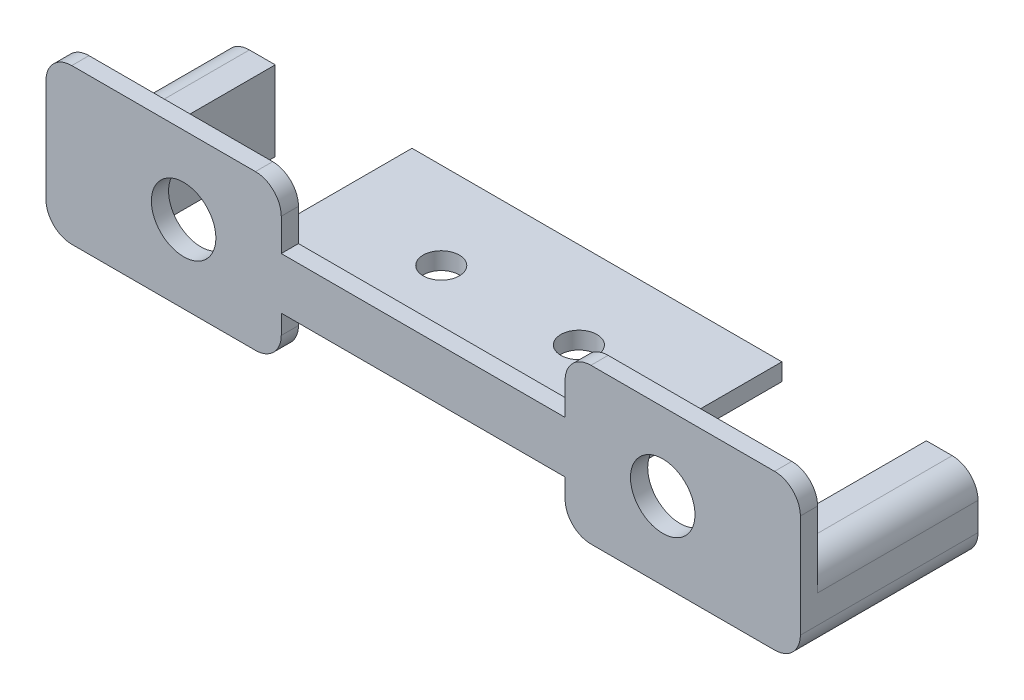
from build123d import *

# Parameters (mm, degrees)
SKETCH3_W           = 43
SKETCH3_H           = 18.2
SKETCH3_R           = 2.1
BOSS_EXTRUDE5_DEPTH = 2
SKETCH1_R           = 3.75
BOSS_EXTRUDE1_DEPTH = 2
CHAMFER1_SIZE       = 1.5
SKETCH5_W           = 6
SKETCH5_H           = 9.25
BOSS_EXTRUDE4_DEPTH = 18.65
FILLET1_R           = 3


with BuildPart() as part:
    # Sketch3 → Boss-Extrude5 (new body)
    with BuildSketch(Plane(origin=(0, 0, 0), x_dir=(1, 0, 0), z_dir=(0, 1, 0))):
        with Locations((0, 9.1)):
            Rectangle(SKETCH3_W, SKETCH3_H)
        with Locations((-8, 8.1)):
            Circle(SKETCH3_R, mode=Mode.SUBTRACT)
        with Locations((8, 8.1)):
            Circle(SKETCH3_R, mode=Mode.SUBTRACT)
    extrude(amount=-BOSS_EXTRUDE5_DEPTH)

    # Sketch1 → Boss-Extrude1 (add)
    with BuildSketch(Plane.XY):
        Polygon((-43.85, -9.25), (-16.5, -9.25), (-16.5, -4), (16.5, -4), (16.5, -9.25), (43.85, -9.25), (43.85, 8.75), (16.5, 8.75), (16.5, 2), (-16.5, 2), (-16.5, 8.75), (-43.85, 8.75), align=None)
        with Locations((-27.85, -0.25)):
            Circle(SKETCH1_R, mode=Mode.SUBTRACT)
        with Locations((27.85, -0.25)):
            Circle(SKETCH1_R, mode=Mode.SUBTRACT)
    extrude(amount=BOSS_EXTRUDE1_DEPTH)

    # Chamfer1
    chamfer1_edges = [part.edges().sort_by_distance(p)[0] for p in [
        (0, -2, 0),
    ]]
    chamfer(chamfer1_edges, length=CHAMFER1_SIZE)

    # Sketch5 → Boss-Extrude4 (add)
    with BuildSketch(Plane(origin=(0, 0, 0), x_dir=(-1, 0, 0), z_dir=(0, 0, -1))):
        with Locations((40.85, -4.625)):
            Rectangle(SKETCH5_W, SKETCH5_H)
    boss_extrude4 = extrude(amount=BOSS_EXTRUDE4_DEPTH)

    # Mirror2: Boss-Extrude4 across plane
    add(boss_extrude4.mirror(Plane(origin=(0, 0, 0), x_dir=(0, 0, 1), z_dir=(1, 0, 0))))

    # Fillet1
    fillet1_edges = [part.edges().sort_by_distance(p)[0] for p in [
        (-43.85, 8.75, 1),
        (-43.85, -9.25, -8.325),
        (-16.5, -9.25, 1),
        (16.5, -9.25, 1),
        (43.85, -9.25, -8.325),
        (43.85, 8.75, 1),
        (16.5, 8.75, 1),
        (-16.5, 8.75, 1),
        (-43.85, 0, -9.325),
        (43.85, 0, -9.325),
    ]]
    fillet(fillet1_edges, radius=FILLET1_R)


solid = part.part
